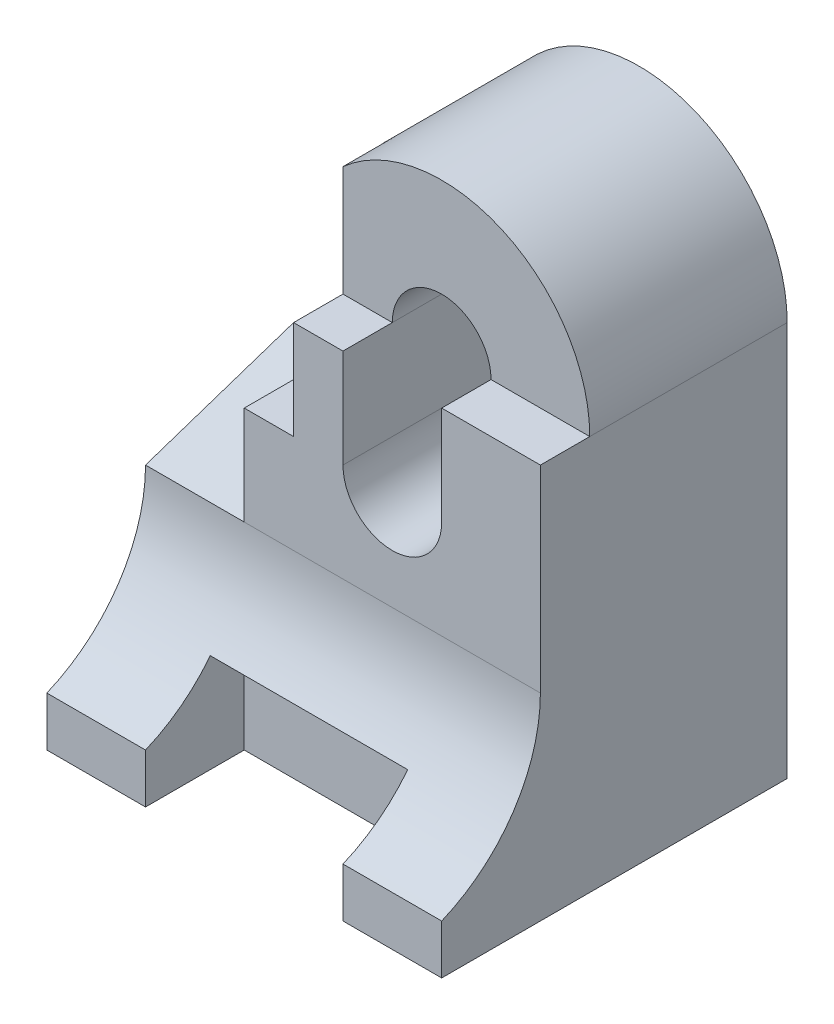
from build123d import *

# Parameters (mm, degrees)
BOSS_EXTRUDE2_DEPTH = 5
BOSS_EXTRUDE3_DEPTH = 8
SKETCH4_W           = 4
SKETCH4_H           = 2
CUT_EXTRUDE2_DEPTH  = 2
CUT_EXTRUDE3_DEPTH  = 1
CUT_EXTRUDE4_DEPTH  = 2
BOSS_EXTRUDE4_DEPTH = 1
BOSS_EXTRUDE5_DEPTH = 2


with BuildPart() as part:
    # Sketch1 → Boss-Extrude2 (new body)
    with BuildSketch(Plane.XY):
        with BuildLine():
            Line((4, 2), (4, 6))
            ThreePointArc((4, 6), (1, 9), (-2, 6))
            Line((-2, 6), (-2, 2))
            Line((-2, 2), (-4, 2))
            Line((-4, 2), (-4, -2))
            Line((-4, -2), (4, -2))
            Line((4, -2), (4, 2))
        make_face()
        with BuildLine():
            Line((2, 6), (2, 4))
            ThreePointArc((2, 4), (1, 3), (0, 4))
            Line((0, 4), (0, 6))
            ThreePointArc((0, 6), (1, 7), (2, 6))
        make_face(mode=Mode.SUBTRACT)
    extrude(amount=BOSS_EXTRUDE2_DEPTH)

    # Sketch2 → Boss-Extrude3 (add)
    with BuildSketch(Plane(origin=(4, 0, 0), x_dir=(0, 0, -1), z_dir=(1, 0, 0))):
        with BuildLine():
            Line((-5, -2), (-7, -2))
            Line((-7, -2), (-7, -1))
            ThreePointArc((-7, -1), (-5.545836543, 0.197224362), (-5, 2))
            Line((-5, 2), (-5, -2))
        make_face()
    extrude(amount=-BOSS_EXTRUDE3_DEPTH)

    # Sketch4 → Cut-Extrude2 (cut)
    with BuildSketch(Plane.XZ.offset(2)):
        with Locations((0, 6)):
            Rectangle(SKETCH4_W, SKETCH4_H)
    extrude(amount=-CUT_EXTRUDE2_DEPTH, mode=Mode.SUBTRACT)

    # Sketch5 → Cut-Extrude3 (cut)
    with BuildSketch(Plane.XY.offset(5)):
        with BuildLine():
            Line((4, 6), (2, 6))
            ThreePointArc((2, 6), (1, 7), (0, 6))
            Line((0, 6), (-2, 6))
            ThreePointArc((-2, 6), (1, 9), (4, 6))
        make_face()
    extrude(amount=-CUT_EXTRUDE3_DEPTH, mode=Mode.SUBTRACT)

    # Sketch6 → Cut-Extrude4 (cut)
    with BuildSketch(Plane.XY.offset(5)):
        with BuildLine():
            Line((-2, 4), (-1, 4))
            Line((-1, 4), (-1, 8.236067977))
            ThreePointArc((-1, 8.236067977), (-1.738612788, 7.224744871), (-2, 6))
            Line((-2, 6), (-2, 4))
        make_face()
    extrude(amount=-CUT_EXTRUDE4_DEPTH, mode=Mode.SUBTRACT)

    # Sketch7 → Boss-Extrude4 (add)
    with BuildSketch(Plane(origin=(0, 0, 0), x_dir=(-1, 0, 0), z_dir=(0, 0, -1))):
        Polygon((4, 2), (4, 3), (2, 6), (2, 2), align=None)
    extrude(amount=-BOSS_EXTRUDE4_DEPTH)

    # Sketch8 → Boss-Extrude5 (add)
    with BuildSketch(Plane.ZY.offset(2)):
        Polygon((1, 2), (1, 3), (2, 3), (5, 2), align=None)
    extrude(amount=BOSS_EXTRUDE5_DEPTH)


solid = part.part
